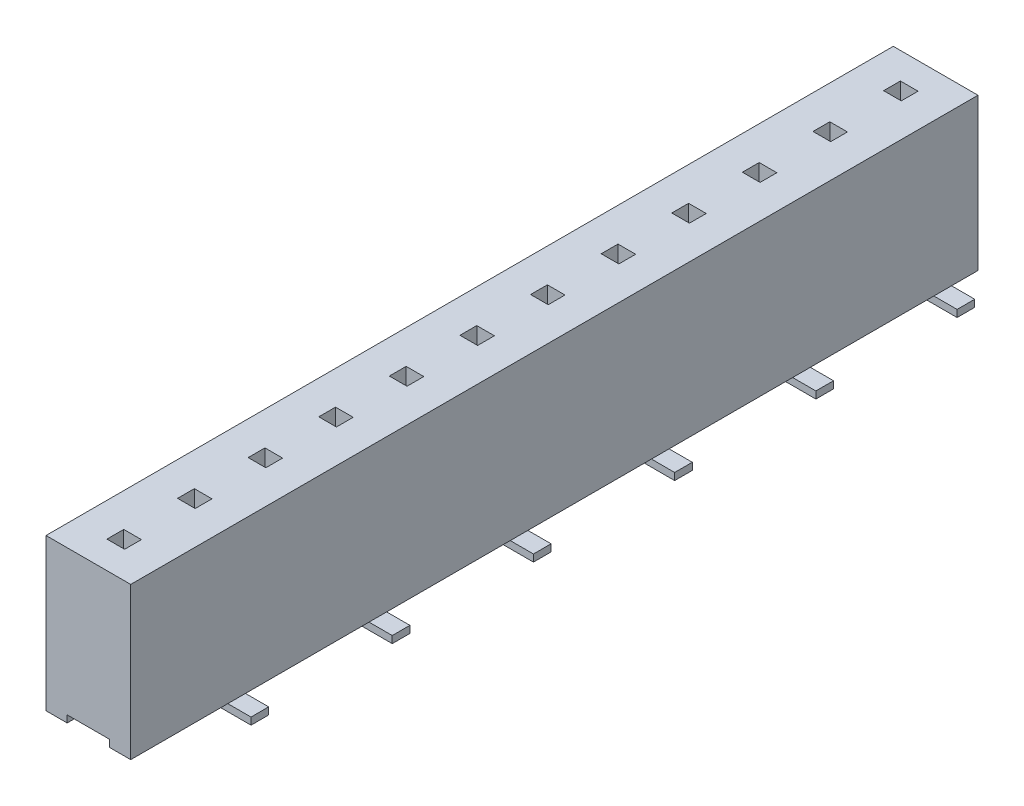
from build123d import *

# Parameters (mm, degrees)
SKETCH1_W           = 2.4
SKETCH1_H           = 4.3
BOSS_EXTRUDE1_DEPTH = 24
SKETCH2_W           = 1.2
SKETCH2_H           = 0.2
CUT_EXTRUDE1_DEPTH  = 25
SKETCH3_W           = 0.5
SKETCH3_H           = 0.5
BOSS_EXTRUDE2_DEPTH = 0.4
SKETCH7_W           = 0.5
SKETCH7_H           = 0.475666933
CUT_EXTRUDE2_DEPTH  = 3.5
SKETCH_1_W          = 0.5
SKETCH_1_H          = 0.2
EXTRUDE_1_DEPTH     = 1.6
SKETCH_2_W          = 0.5
SKETCH_2_H          = 0.2
EXTRUDE_2_DEPTH     = 1.6
EXTRUDE_2_2_DEPTH   = 1.6
EXTRUDE_2_3_DEPTH   = 1.6
EXTRUDE_2_4_DEPTH   = 1.6
EXTRUDE_2_5_DEPTH   = 1.6
EXTRUDE_2_6_DEPTH   = 1.6


with BuildPart() as part:
    # Sketch1 → Boss-Extrude1 (new body)
    with BuildSketch(Plane.XY):
        with Locations((1.2, -2.15)):
            Rectangle(SKETCH1_W, SKETCH1_H)
    extrude(amount=-BOSS_EXTRUDE1_DEPTH)

    # Sketch2 → Cut-Extrude1 (cut, through all)
    with BuildSketch(Plane.XY):
        with Locations((1.2, -4.2)):
            Rectangle(SKETCH2_W, SKETCH2_H)
    extrude(amount=-CUT_EXTRUDE1_DEPTH, mode=Mode.SUBTRACT)

    # Sketch3 → Boss-Extrude2 (add)
    with BuildSketch(Plane(origin=(0, -4.1, 0), x_dir=(-1, 0, 0), z_dir=(0, -1, 0))):
        with Locations((-1.207554148, 1)):
            Rectangle(SKETCH3_W, SKETCH3_H)
        with Locations((-1.207554148, 3)):
            Rectangle(SKETCH3_W, SKETCH3_H)
        with Locations((-1.207554148, 5)):
            Rectangle(SKETCH3_W, SKETCH3_H)
        with Locations((-1.207554148, 7)):
            Rectangle(SKETCH3_W, SKETCH3_H)
        with Locations((-1.207554148, 9)):
            Rectangle(SKETCH3_W, SKETCH3_H)
        with Locations((-1.207554148, 11)):
            Rectangle(SKETCH3_W, SKETCH3_H)
        with Locations((-1.207554148, 13)):
            Rectangle(SKETCH3_W, SKETCH3_H)
        with Locations((-1.207554148, 15)):
            Rectangle(SKETCH3_W, SKETCH3_H)
        with Locations((-1.207554148, 17)):
            Rectangle(SKETCH3_W, SKETCH3_H)
        with Locations((-1.207554148, 19)):
            Rectangle(SKETCH3_W, SKETCH3_H)
        with Locations((-1.207554148, 21)):
            Rectangle(SKETCH3_W, SKETCH3_H)
        with Locations((-1.207554148, 23)):
            Rectangle(SKETCH3_W, SKETCH3_H)
    extrude(amount=BOSS_EXTRUDE2_DEPTH)

    # Sketch7 → Cut-Extrude2 (cut)
    with BuildSketch(Plane(origin=(0, 0, 0), x_dir=(1, 0, 0), z_dir=(0, 1, 0))):
        with Locations((1.201899432, 21.012166534)):
            Rectangle(SKETCH7_W, SKETCH7_H)
        with Locations((1.201899432, 23.012166534)):
            Rectangle(SKETCH7_W, SKETCH7_H)
        with Locations((1.201899432, 19.012166534)):
            Rectangle(SKETCH7_W, SKETCH7_H)
        with Locations((1.201899432, 17.012166534)):
            Rectangle(SKETCH7_W, SKETCH7_H)
        with Locations((1.201899432, 15.012166534)):
            Rectangle(SKETCH7_W, SKETCH7_H)
        with Locations((1.201899432, 13.012166534)):
            Rectangle(SKETCH7_W, SKETCH7_H)
        with Locations((1.201899432, 11.012166534)):
            Rectangle(SKETCH7_W, SKETCH7_H)
        with Locations((1.201899432, 9.012166534)):
            Rectangle(SKETCH7_W, SKETCH7_H)
        with Locations((1.201899432, 7.012166534)):
            Rectangle(SKETCH7_W, SKETCH7_H)
        with Locations((1.201899432, 5.012166534)):
            Rectangle(SKETCH7_W, SKETCH7_H)
        with Locations((1.201899432, 3.012166534)):
            Rectangle(SKETCH7_W, SKETCH7_H)
        with Locations((1.201899432, 1.012166534)):
            Rectangle(SKETCH7_W, SKETCH7_H)
    extrude(amount=-CUT_EXTRUDE2_DEPTH, mode=Mode.SUBTRACT)

    # ｽｹｯﾁ1 → ﾎﾞｽ - 押し出し1 (add)
    with BuildSketch(Plane(origin=(1.457554148, 0, 0), x_dir=(0, 0, -1), z_dir=(1, 0, 0))):
        with Locations((23, -4.4)):
            Rectangle(SKETCH_1_W, SKETCH_1_H)
        with Locations((19, -4.4)):
            Rectangle(SKETCH_1_W, SKETCH_1_H)
        with Locations((15, -4.4)):
            Rectangle(SKETCH_1_W, SKETCH_1_H)
        with Locations((11, -4.4)):
            Rectangle(SKETCH_1_W, SKETCH_1_H)
        with Locations((7, -4.4)):
            Rectangle(SKETCH_1_W, SKETCH_1_H)
        with Locations((3, -4.4)):
            Rectangle(SKETCH_1_W, SKETCH_1_H)
    extrude(amount=EXTRUDE_1_DEPTH)


with BuildPart() as body_2:
    # ｽｹｯﾁ2 → ﾎﾞｽ - 押し出し2 (new body)
    with BuildSketch(Plane.ZY.offset(-0.957554148)):
        with Locations((-1, -4.4)):
            Rectangle(SKETCH_2_W, SKETCH_2_H)
    extrude(amount=EXTRUDE_2_DEPTH)


with BuildPart() as body_3:
    # ｽｹｯﾁ2 → Extrude 2 2 (new body)
    with BuildSketch(Plane.ZY.offset(-0.957554148)):
        with Locations((-5, -4.4)):
            Rectangle(SKETCH_2_W, SKETCH_2_H)
    extrude(amount=EXTRUDE_2_2_DEPTH)


with BuildPart() as body_4:
    # ｽｹｯﾁ2 → Extrude 2 3 (new body)
    with BuildSketch(Plane.ZY.offset(-0.957554148)):
        with Locations((-9, -4.4)):
            Rectangle(SKETCH_2_W, SKETCH_2_H)
    extrude(amount=EXTRUDE_2_3_DEPTH)


with BuildPart() as body_5:
    # ｽｹｯﾁ2 → Extrude 2 4 (new body)
    with BuildSketch(Plane.ZY.offset(-0.957554148)):
        with Locations((-13, -4.4)):
            Rectangle(SKETCH_2_W, SKETCH_2_H)
    extrude(amount=EXTRUDE_2_4_DEPTH)


with BuildPart() as body_6:
    # ｽｹｯﾁ2 → Extrude 2 5 (new body)
    with BuildSketch(Plane.ZY.offset(-0.957554148)):
        with Locations((-17, -4.4)):
            Rectangle(SKETCH_2_W, SKETCH_2_H)
    extrude(amount=EXTRUDE_2_5_DEPTH)


with BuildPart() as body_7:
    # ｽｹｯﾁ2 → Extrude 2 6 (new body)
    with BuildSketch(Plane.ZY.offset(-0.957554148)):
        with Locations((-21, -4.4)):
            Rectangle(SKETCH_2_W, SKETCH_2_H)
    extrude(amount=EXTRUDE_2_6_DEPTH)


solid = Compound([part.part, body_2.part, body_3.part, body_4.part, body_5.part, body_6.part, body_7.part])
